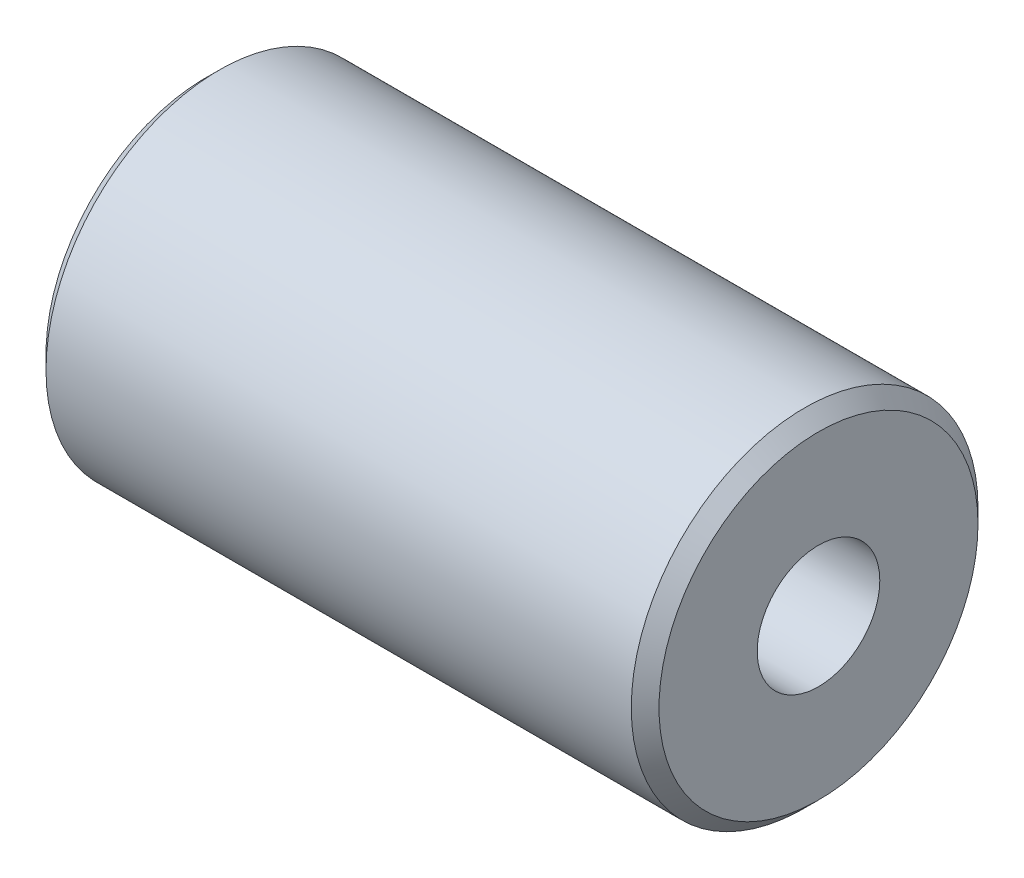
from build123d import *

# Parameters (mm, degrees)
EXTRUDE1_START = -22.1
SKETCH1_R      = 12.5
SKETCH1_R_2    = 4.4196
EXTRUDE1_DEPTH = 44.2
CHAMFER1_SIZE  = 1


with BuildPart() as part:
    # Sketch1 → Extrude1 (new body)
    with BuildSketch(Plane(origin=(0, 0, 0), x_dir=(0, 0, -1), z_dir=(1, 0, 0)).offset(EXTRUDE1_START)):
        Circle(SKETCH1_R)
        Circle(SKETCH1_R_2, mode=Mode.SUBTRACT)
    extrude(amount=EXTRUDE1_DEPTH)

    # Chamfer1
    chamfer1_edges = [part.edges().sort_by_distance(p)[0] for p in [
        (-22.1, 0, 12.5),
        (22.1, 0, 12.5),
    ]]
    chamfer(chamfer1_edges, length=CHAMFER1_SIZE)


solid = part.part
